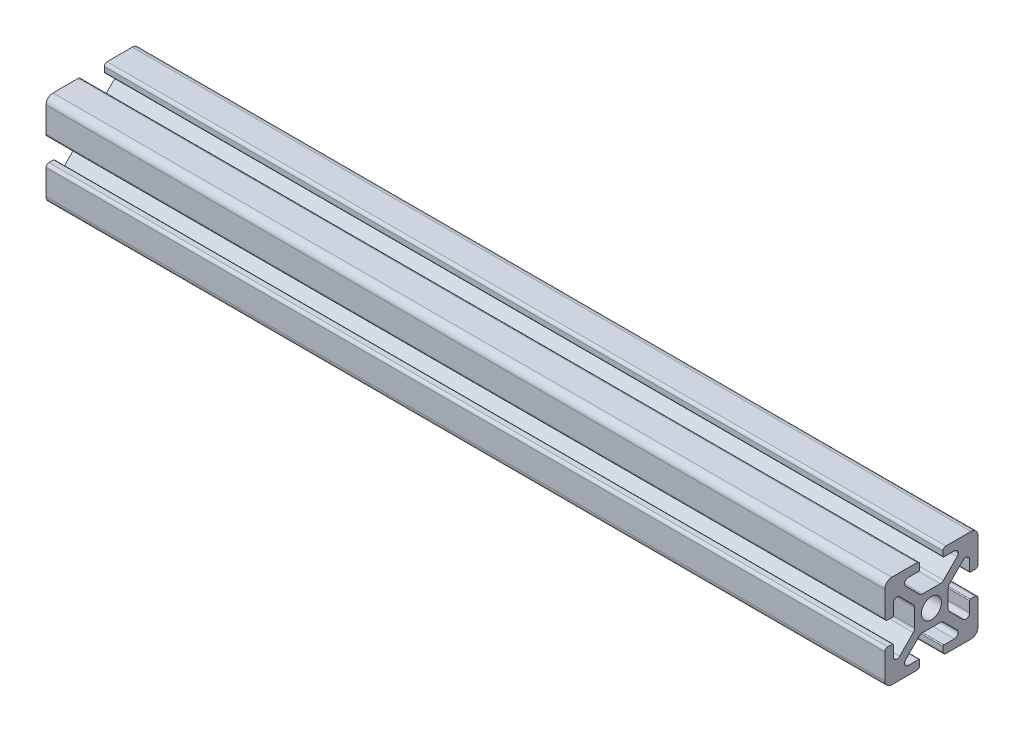
from build123d import *

# Parameters (mm, degrees)
BOSS_EXTRUDE1_DEPTH = 180


with BuildPart() as part:
    # Sketch3 → Boss-Extrude1 (new body)
    with BuildSketch(Plane(origin=(0, 0, 0), x_dir=(0, 0, -1), z_dir=(1, 0, 0))):
        with BuildLine():
            Line((-5.515685425, 6.807463915), (-2.601114729, 3.892893219))
            ThreePointArc((-2.601114729, 3.892893219), (-2.27669138, 3.676120467), (-1.894007948, 3.6))
            Line((-1.894007948, 3.6), (0, 3.6))
            Line((0, 3.6), (0, 2.15))
            ThreePointArc((0, 2.15), (-1.52027958, 1.52027958), (-2.15, 0))
            Line((-2.15, 0), (-3.6, 0))
            Line((-3.6, 0), (-3.6, 1.894007948))
            ThreePointArc((-3.6, 1.894007948), (-3.676120467, 2.27669138), (-3.892893219, 2.601114729))
            Line((-3.892893219, 2.601114729), (-6.807463915, 5.515685425))
            ThreePointArc((-6.807463915, 5.515685425), (-7.679296086, 5.689103626), (-8.17314934, 4.95))
            Line((-8.17314934, 4.95), (-8.17314934, 2.7))
            ThreePointArc((-8.17314934, 2.7), (-8.231727984, 2.558578644), (-8.37314934, 2.5))
            Line((-8.37314934, 2.5), (-9.4, 2.5))
            ThreePointArc((-9.4, 2.5), (-9.824264069, 2.675735931), (-10, 3.1))
            Line((-10, 3.1), (-10, 8.5))
            ThreePointArc((-10, 8.5), (-9.560660172, 9.560660172), (-8.5, 10))
            Line((-8.5, 10), (-3.1, 10))
            ThreePointArc((-3.1, 10), (-2.675735931, 9.824264069), (-2.5, 9.4))
            Line((-2.5, 9.4), (-2.5, 8.37314934))
            ThreePointArc((-2.5, 8.37314934), (-2.558578644, 8.231727984), (-2.7, 8.17314934))
            Line((-2.7, 8.17314934), (-4.95, 8.17314934))
            ThreePointArc((-4.95, 8.17314934), (-5.689103626, 7.679296086), (-5.515685425, 6.807463915))
        make_face()
    extrude(amount=-BOSS_EXTRUDE1_DEPTH)

    # Mirror1: part across plane


with BuildPart() as part_1:
    add(part.part)
    add(part.part.mirror(Plane.ZX))

    # Mirror2: part across plane


with BuildPart() as part_2:
    add(part_1.part)
    add(part_1.part.mirror(Plane.XY))


solid = part_2.part
